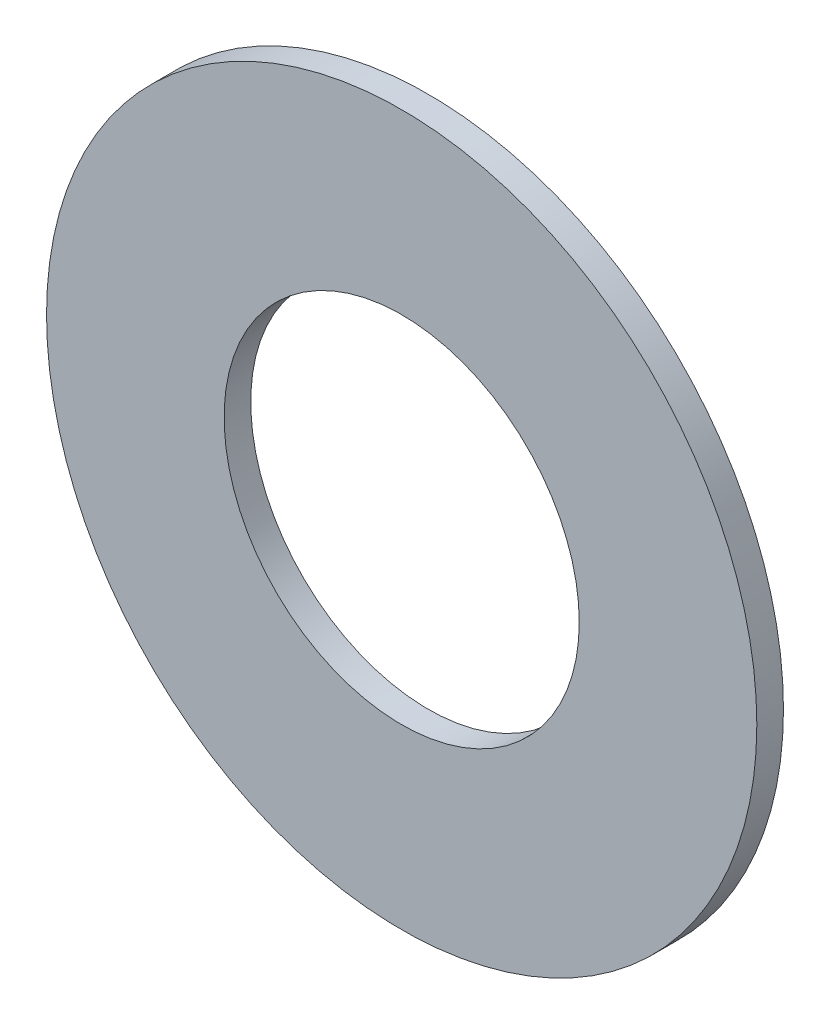
from build123d import *

# Parameters (mm, degrees)
SKETCH1_R           = 16
SKETCH1_R_2         = 8
BOSS_EXTRUDE1_DEPTH = 1.2


with BuildPart() as part:
    # Sketch1 → Boss-Extrude1 (new body)
    with BuildSketch(Plane(origin=(0, 0, 0), x_dir=(0, 1, 0), z_dir=(0, 0, 1))):
        Circle(SKETCH1_R)
        Circle(SKETCH1_R_2, mode=Mode.SUBTRACT)
    extrude(amount=BOSS_EXTRUDE1_DEPTH)


solid = part.part
